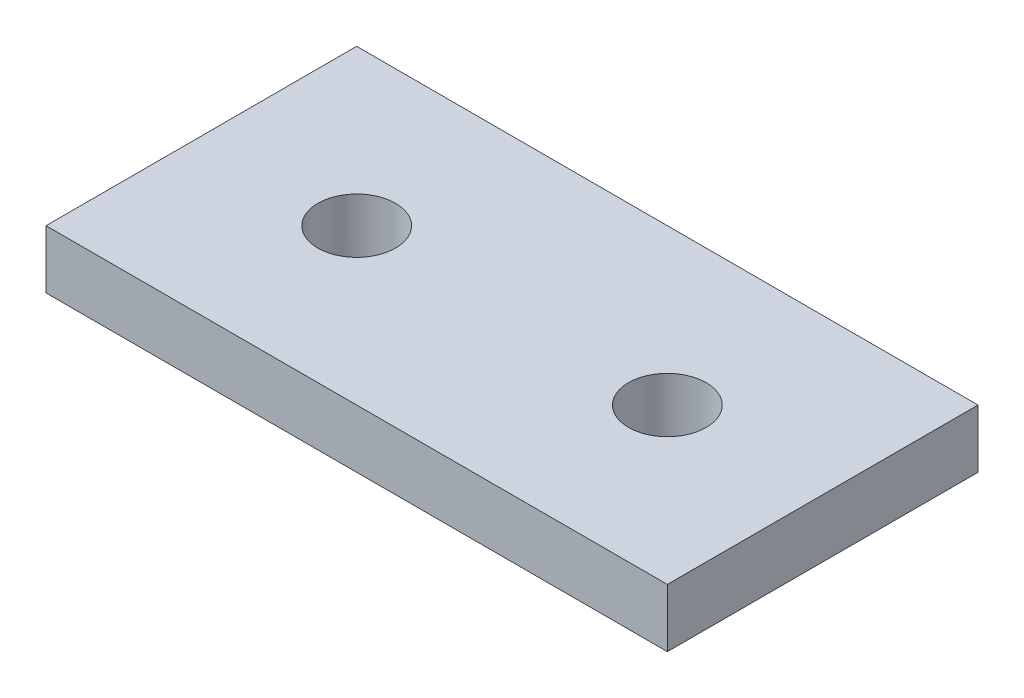
from build123d import *

# Parameters (mm, degrees)
SKETCH1_W           = 50.8
SKETCH1_H           = 25.4
BOSS_EXTRUDE1_DEPTH = 2.38125
CUT_EXTRUDE1_REACH  = 6.763
SKETCH2_R           = 3.175


with BuildPart() as part:
    # Sketch1 → Boss-Extrude1 (new body, symmetric)
    with BuildSketch(Plane(origin=(0, 0, 0), x_dir=(1, 0, 0), z_dir=(0, 1, 0))):
        Rectangle(SKETCH1_W, SKETCH1_H)
    extrude(amount=BOSS_EXTRUDE1_DEPTH, both=True)

    # Sketch2 → Cut-Extrude1 (cut, up to next)
    with BuildSketch(Plane(origin=(0, 2.38125, 0), x_dir=(1, 0, 0), z_dir=(0, 1, 0)), mode=Mode.PRIVATE) as cut_extrude1_sk1:
        with Locations((-12.7, 0)):
            Circle(SKETCH2_R)
    cut_extrude1_tool1 = extrude(cut_extrude1_sk1.sketch, amount=-CUT_EXTRUDE1_REACH, mode=Mode.PRIVATE) & part.part
    add(cut_extrude1_tool1.solids().sort_by_distance((-12.7, 2.38125, 0))[0], mode=Mode.SUBTRACT)
    # Sketch2 → Cut-Extrude1 (cut, up to next)
    with BuildSketch(Plane(origin=(0, 2.38125, 0), x_dir=(1, 0, 0), z_dir=(0, 1, 0)), mode=Mode.PRIVATE) as cut_extrude1_sk2:
        with Locations((12.7, 0)):
            Circle(SKETCH2_R)
    cut_extrude1_tool2 = extrude(cut_extrude1_sk2.sketch, amount=-CUT_EXTRUDE1_REACH, mode=Mode.PRIVATE) & part.part
    add(cut_extrude1_tool2.solids().sort_by_distance((12.7, 2.38125, 0))[0], mode=Mode.SUBTRACT)


solid = part.part
